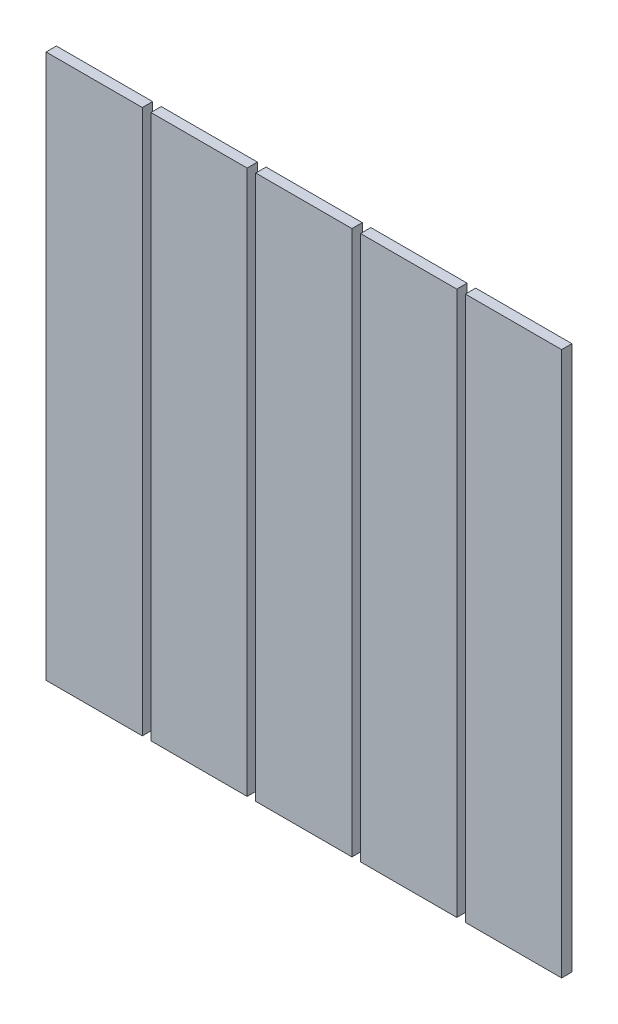
from build123d import *

# Parameters (mm, degrees)
CROQUIS1_W              = 900
CROQUIS1_H              = 950
SALIENTE_EXTRUIR1_DEPTH = 18
CROQUIS2_W              = 15
CROQUIS2_H              = 950
CORTAR_EXTRUIR1_DEPTH   = 18


with BuildPart() as part:
    # Croquis1 → Saliente-Extruir1 (new body)
    with BuildSketch(Plane.XY):
        with Locations((-450, 475)):
            Rectangle(CROQUIS1_W, CROQUIS1_H)
    extrude(amount=SALIENTE_EXTRUIR1_DEPTH)

    # Croquis2 → Cortar-Extruir1 (cut)
    with BuildSketch(Plane.XY.offset(18)):
        with Locations((-724.5, 475)):
            Rectangle(CROQUIS2_W, CROQUIS2_H)
        with Locations((-175.5, 475)):
            Rectangle(CROQUIS2_W, CROQUIS2_H)
        with Locations((-358.5, 475)):
            Rectangle(CROQUIS2_W, CROQUIS2_H)
        with Locations((-541.5, 475)):
            Rectangle(CROQUIS2_W, CROQUIS2_H)
    extrude(amount=-CORTAR_EXTRUIR1_DEPTH, mode=Mode.SUBTRACT)


solid = part.part
